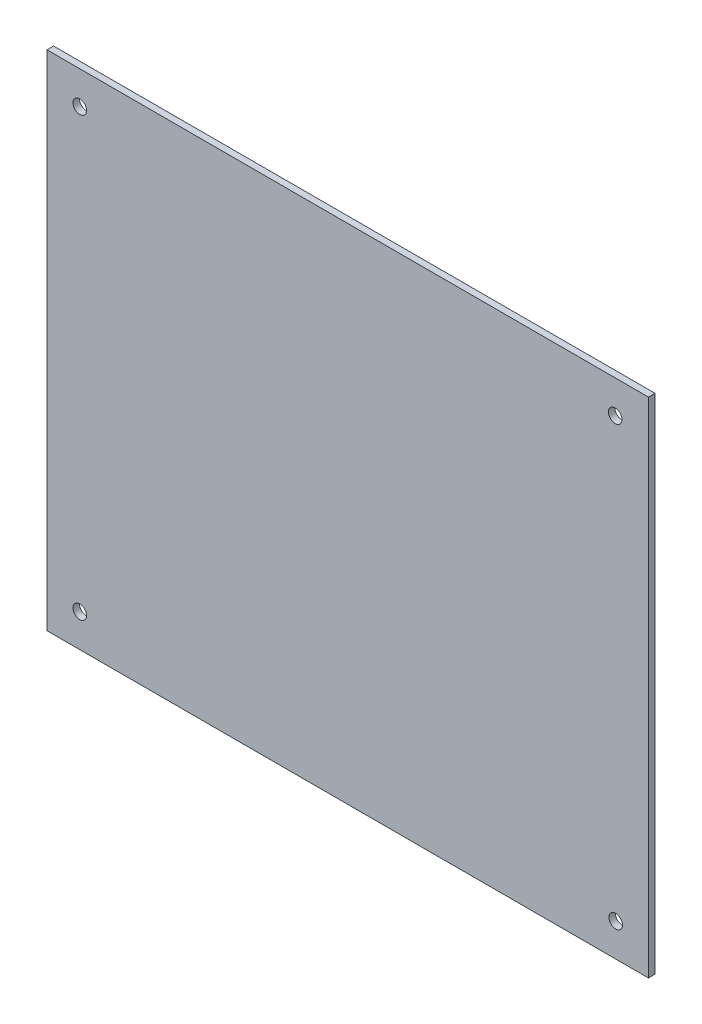
from build123d import *

# Parameters (mm, degrees)
CROQUIS1_W              = 275
CROQUIS1_H              = 230
CROQUIS1_R              = 3.1
SALIENTE_EXTRUIR1_DEPTH = 3


with BuildPart() as part:
    # Croquis1 → Saliente-Extruir1 (new body)
    with BuildSketch(Plane.XY):
        Rectangle(CROQUIS1_W, CROQUIS1_H)
        with Locations((-122.5, 100)):
            Circle(CROQUIS1_R, mode=Mode.SUBTRACT)
        with Locations((122.275174875, 100)):
            Circle(CROQUIS1_R, mode=Mode.SUBTRACT)
        with Locations((-122.5, -100)):
            Circle(CROQUIS1_R, mode=Mode.SUBTRACT)
        with Locations((122.5, -100)):
            Circle(CROQUIS1_R, mode=Mode.SUBTRACT)
    extrude(amount=SALIENTE_EXTRUIR1_DEPTH)


solid = part.part
